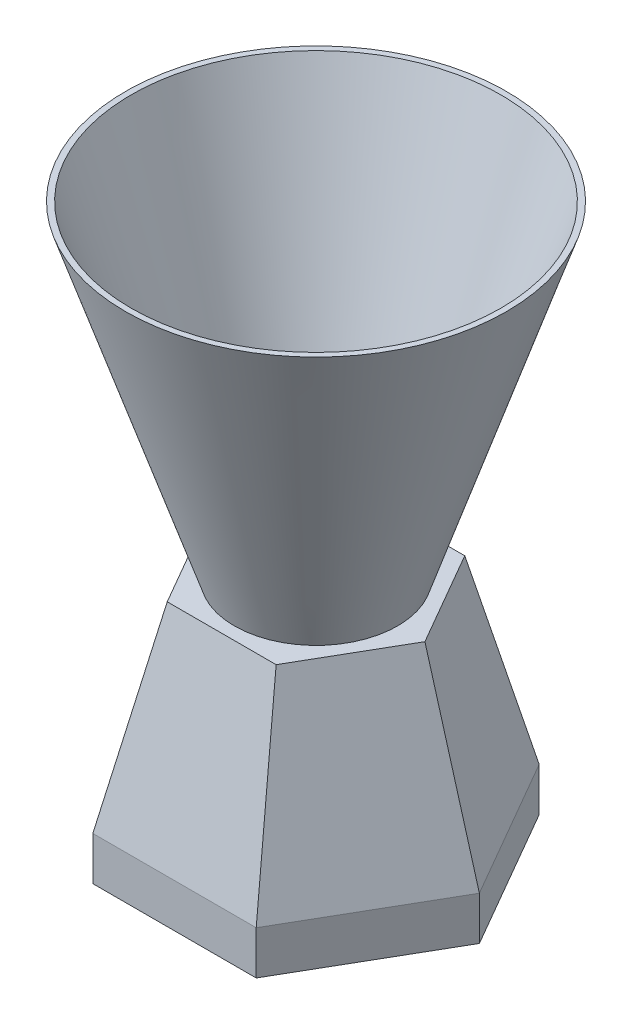
from build123d import *

# Parameters (mm, degrees)
EXTRUDE1_DEPTH = 8


with BuildPart() as part:
    # Sketch1 → Extrude1 (new body)
    with BuildSketch(Plane(origin=(0, 0, 0), x_dir=(1, 0, 0), z_dir=(0, 1, 0))):
        Polygon((30, 0), (15, 25.980762114), (-15, 25.980762114), (-30, 0), (-15, -25.980762114), (15, -25.980762114), align=None)
    extrude(amount=EXTRUDE1_DEPTH)

    # Sketch2 → Loft1 section 0
    with BuildSketch(Plane(origin=(0, 8, 0), x_dir=(1, 0, 0), z_dir=(0, 1, 0))):
        Polygon((30, 0), (15, 25.980762114), (-15, 25.980762114), (-30, 0), (-15, -25.980762114), (15, -25.980762114), align=None)
    # Sketch3 → Loft1 section 1
    with BuildSketch(Plane(origin=(0, 43, 0), x_dir=(-1, 0, 0), z_dir=(0, 1, 0))):
        Polygon((20, 0), (10, 17.320508076), (-10, 17.320508076), (-20, 0), (-10, -17.320508076), (10, -17.320508076), align=None)
    loft()

    # Sketch4 → Revolve1 (revolve)
    with BuildSketch(Plane.XY, mode=Mode.PRIVATE) as revolve1_sk:
        Polygon((35, 103), (15, 43), (13.945907447, 43), (33.945907447, 103), align=None)
    revolve(revolve1_sk.sketch.rotate(Axis((0, 43, 0), (0, 1, 0)), 270), axis=Axis((0, 43, 0), (0, 1, 0)))  # turned: the seam where the file's is


solid = part.part
